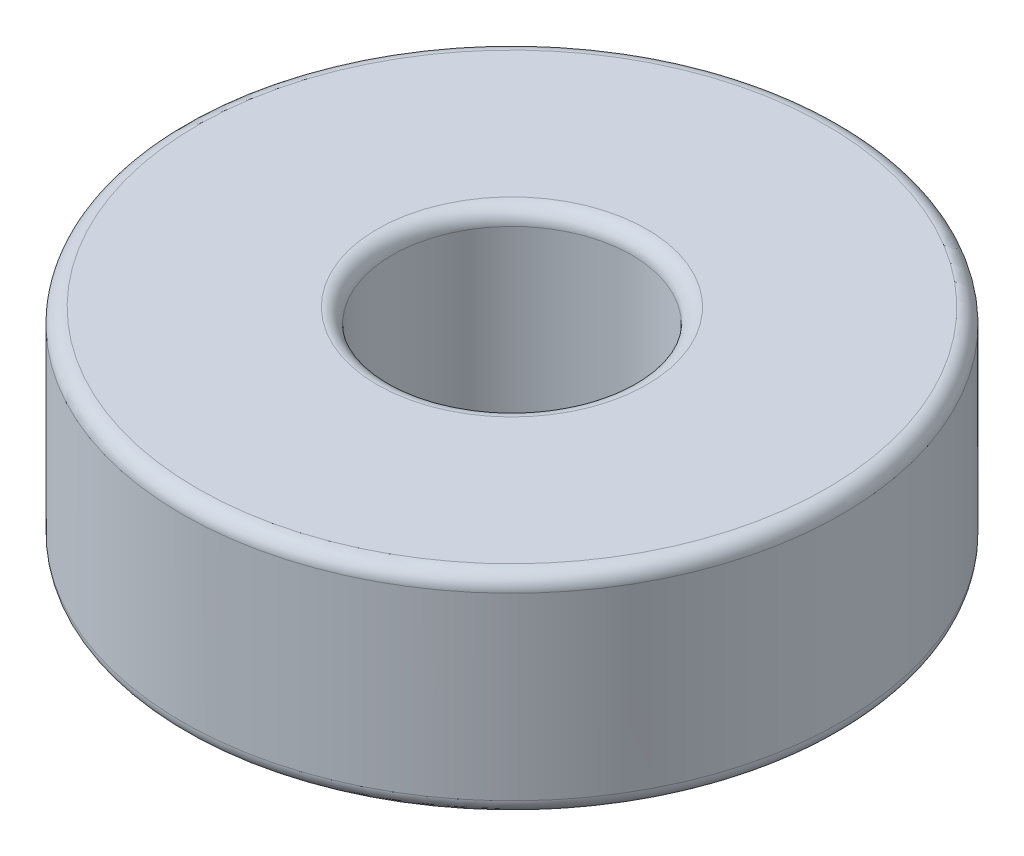
from build123d import *

# Parameters (mm, degrees)
ESQUISSE1_W = 7
ESQUISSE1_H = 7
CONG_1_R    = 0.5


with BuildPart() as part:
    # Esquisse1 → Révolution1 (revolve)
    with BuildSketch(Plane.XY):
        with Locations((7.5, 3.5)):
            Rectangle(ESQUISSE1_W, ESQUISSE1_H)
    revolve(axis=Axis((0, 0, 0), (0, 1, 0)))

    # Congé1
    cong_1_edges = [part.edges().sort_by_distance(p)[0] for p in [
        (-4, 0, 0),
        (-11, 0, 0),
        (-11, 7, 0),
        (-4, 7, 0),
    ]]
    fillet(cong_1_edges, radius=CONG_1_R)


solid = part.part
